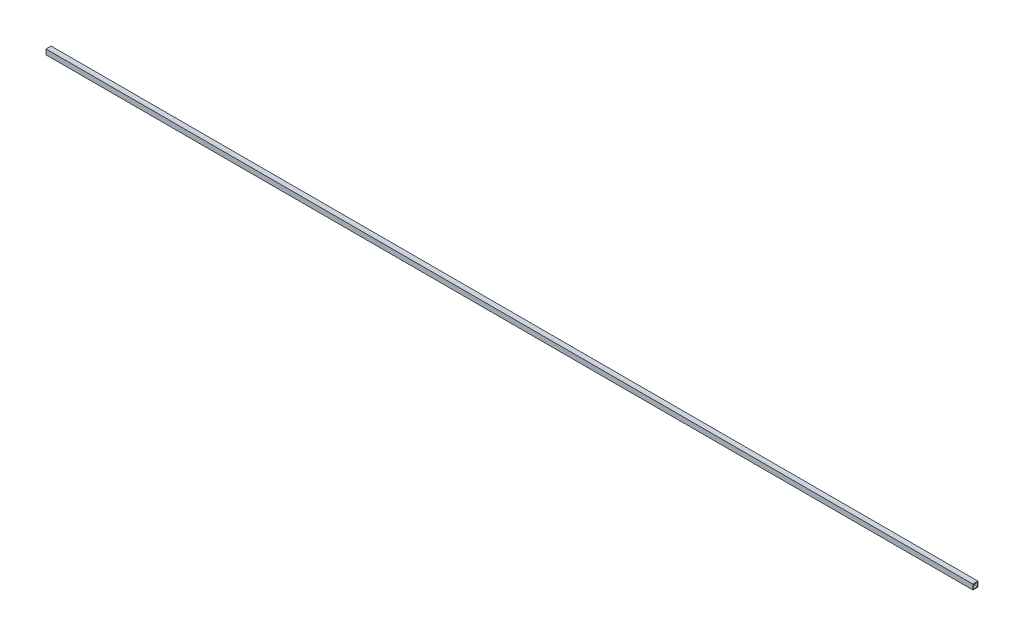
from build123d import *

# Parameters (mm, degrees)
SKETCH1_W                                      = 50.8
SKETCH1_H                                      = 50.8
SKETCH1_W_2                                    = 38.1
SKETCH1_H_2                                    = 38.1
AL_TUBE_SQUARE_AL_TUBE_2_SQR_X_0_25_WALL_DEPTH = 9206.23


with BuildPart() as part:
    # Sketch1 → Al tube square AL TUBE 2 SQR X 0.25 WALL(1) (new body)
    with BuildSketch(Plane.YZ):
        Rectangle(SKETCH1_W, SKETCH1_H)
        Rectangle(SKETCH1_W_2, SKETCH1_H_2, mode=Mode.SUBTRACT)
    extrude(amount=AL_TUBE_SQUARE_AL_TUBE_2_SQR_X_0_25_WALL_DEPTH)


solid = part.part
